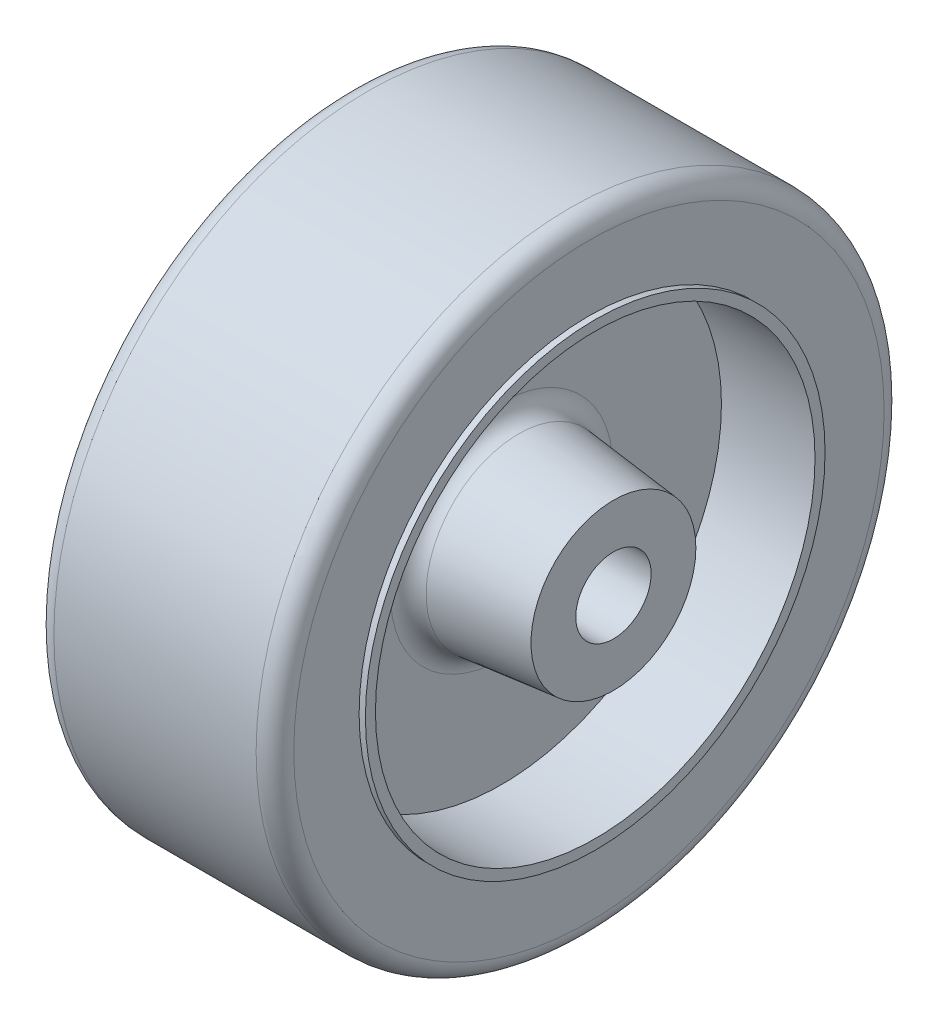
from build123d import *

# Parameters (mm, degrees)
ESQUISSE1_R             = 25
BOSS_EXTRU_1_DEPTH      = 19.1
ESQUISSE2_R             = 18.3
BOSS_EXTRU_2_DEPTH      = 0.5
CONG_1_R                = 1.5
ESQUISSE3_R             = 18.3
BOSS_EXTRU_3_DEPTH      = 0.5
ESQUISSE4_R             = 17.5
ENL_V_MAT_EXTRU_1_DEPTH = 7.45
ESQUISSE5_R             = 17.5
ENL_V_MAT_EXTRU_2_DEPTH = 7.45
ESQUISSE6_R             = 7.5
BOSS_EXTRU_4_DEPTH      = 8.9
BOSS_EXTRU_4_TAPER      = 6
CONG_2_R                = 1.5
ESQUISSE7_R             = 7.5
BOSS_EXTRU_5_DEPTH      = 8.9
BOSS_EXTRU_5_TAPER      = 6
CONG_3_R                = 1.5
ESQUISSE8_R             = 3
ENL_V_MAT_EXTRU_3_DEPTH = 28.9


with BuildPart() as part:
    # Esquisse1 → Boss.-Extru.1 (new body)
    with BuildSketch(Plane(origin=(0, 0, 0), x_dir=(0, 0, -1), z_dir=(1, 0, 0))):
        Circle(ESQUISSE1_R)
    extrude(amount=BOSS_EXTRU_1_DEPTH)

    # Esquisse2 → Boss.-Extru.2 (add)
    with BuildSketch(Plane(origin=(19.1, 0, 0), x_dir=(0, 0, -1), z_dir=(1, 0, 0))):
        Circle(ESQUISSE2_R)
    extrude(amount=BOSS_EXTRU_2_DEPTH)

    # Congé1
    cong_1_edges = [part.edges().sort_by_distance(p)[0] for p in [
        (0, 0, 25),
        (19.1, 0, 25),
    ]]
    fillet(cong_1_edges, radius=CONG_1_R)

    # Esquisse3 → Boss.-Extru.3 (add)
    with BuildSketch(Plane.ZY):
        Circle(ESQUISSE3_R)
    extrude(amount=BOSS_EXTRU_3_DEPTH)

    # Esquisse4 → Enlèv. mat.-Extru.1 (cut)
    with BuildSketch(Plane.ZY.offset(0.5)):
        Circle(ESQUISSE4_R)
    extrude(amount=-ENL_V_MAT_EXTRU_1_DEPTH, mode=Mode.SUBTRACT)

    # Esquisse5 → Enlèv. mat.-Extru.2 (cut)
    with BuildSketch(Plane(origin=(19.6, 0, 0), x_dir=(0, 0, -1), z_dir=(1, 0, 0))):
        Circle(ESQUISSE5_R)
    extrude(amount=-ENL_V_MAT_EXTRU_2_DEPTH, mode=Mode.SUBTRACT)

    # Esquisse6 → Boss.-Extru.4 (add)
    with BuildSketch(Plane(origin=(12.15, 0, 0), x_dir=(0, 0, -1), z_dir=(1, 0, 0))):
        Circle(ESQUISSE6_R)
    extrude(amount=BOSS_EXTRU_4_DEPTH, taper=BOSS_EXTRU_4_TAPER)

    # Congé2
    cong_2_edges = [part.edges().sort_by_distance(p)[0] for p in [
        (12.15, 0, 7.5),
    ]]
    fillet(cong_2_edges, radius=CONG_2_R)

    # Esquisse7 → Boss.-Extru.5 (add)
    with BuildSketch(Plane.ZY.offset(-6.95)):
        Circle(ESQUISSE7_R)
    extrude(amount=BOSS_EXTRU_5_DEPTH, taper=BOSS_EXTRU_5_TAPER)

    # Congé3
    cong_3_edges = [part.edges().sort_by_distance(p)[0] for p in [
        (6.95, 0, -7.5),
    ]]
    fillet(cong_3_edges, radius=CONG_3_R)

    # Esquisse8 → Enlèv. mat.-Extru.3 (cut)
    with BuildSketch(Plane.ZY.offset(1.95)):
        Circle(ESQUISSE8_R)
    extrude(amount=-ENL_V_MAT_EXTRU_3_DEPTH, mode=Mode.SUBTRACT)


solid = part.part
